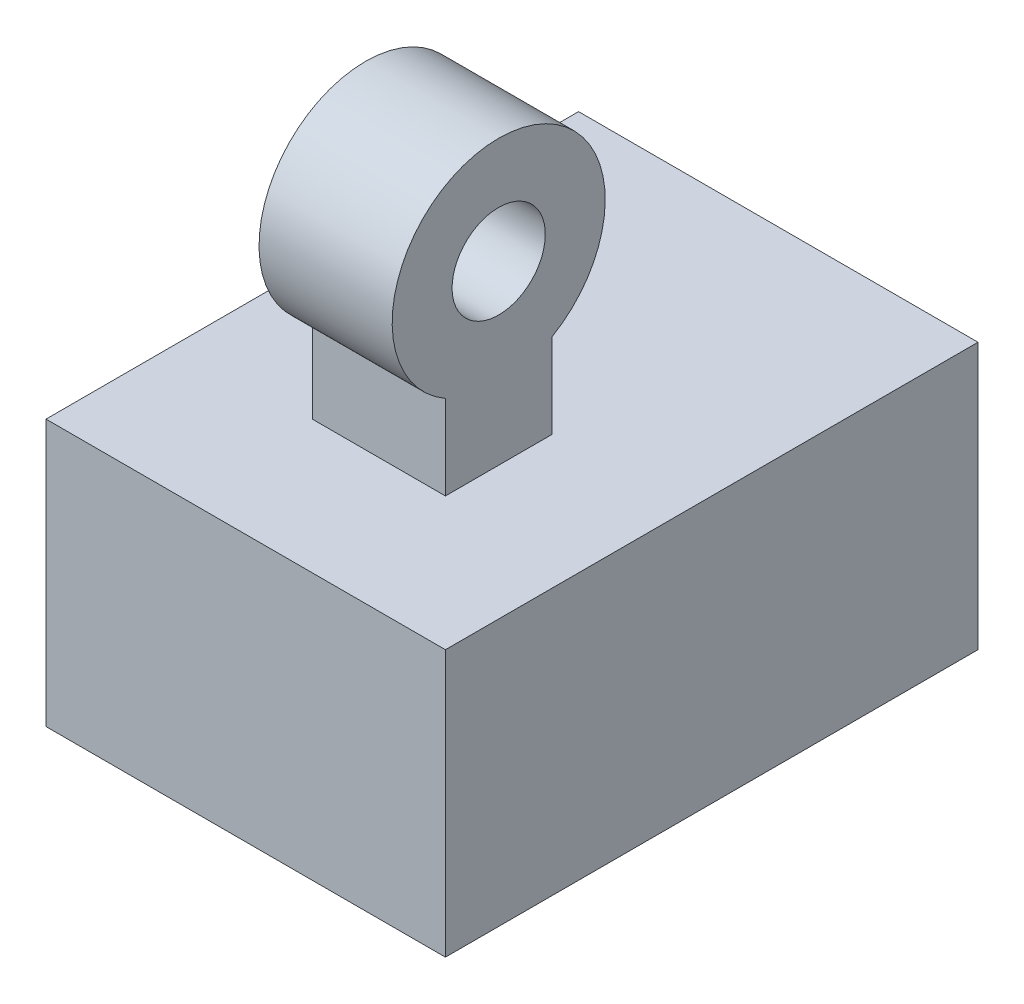
from build123d import *

# Parameters (mm, degrees)
ESQUISSE1_W        = 30
ESQUISSE1_H        = 20
BOSS_EXTRU_1_DEPTH = 40
ESQUISSE3_W        = 10
ESQUISSE3_H        = 8
BOSS_EXTRU_2_DEPTH = 8
ESQUISSE6_R        = 8
ESQUISSE6_R_2      = 3.5
BOSS_EXTRU_3_DEPTH = 10


with BuildPart() as part:
    # Esquisse1 → Boss.-Extru.1 (new body)
    with BuildSketch(Plane.XY):
        with Locations((-56.95643744, 10.673454793)):
            Rectangle(ESQUISSE1_W, ESQUISSE1_H)
    extrude(amount=BOSS_EXTRU_1_DEPTH)

    # Esquisse3 → Boss.-Extru.2 (add)
    with BuildSketch(Plane(origin=(0, 20.673454793, 0), x_dir=(1, 0, 0), z_dir=(0, 1, 0))):
        with Locations((-56.95643744, -26)):
            Rectangle(ESQUISSE3_W, ESQUISSE3_H)
    extrude(amount=BOSS_EXTRU_2_DEPTH)

    # Esquisse6 → Boss.-Extru.3 (add)
    with BuildSketch(Plane(origin=(-51.95643744, 0, 0), x_dir=(0, 0, -1), z_dir=(1, 0, 0))):
        with Locations((-26, 33.944580359)):
            Circle(ESQUISSE6_R)
        with Locations((-26, 33.944580359)):
            Circle(ESQUISSE6_R_2, mode=Mode.SUBTRACT)
    extrude(amount=-BOSS_EXTRU_3_DEPTH)


solid = part.part
